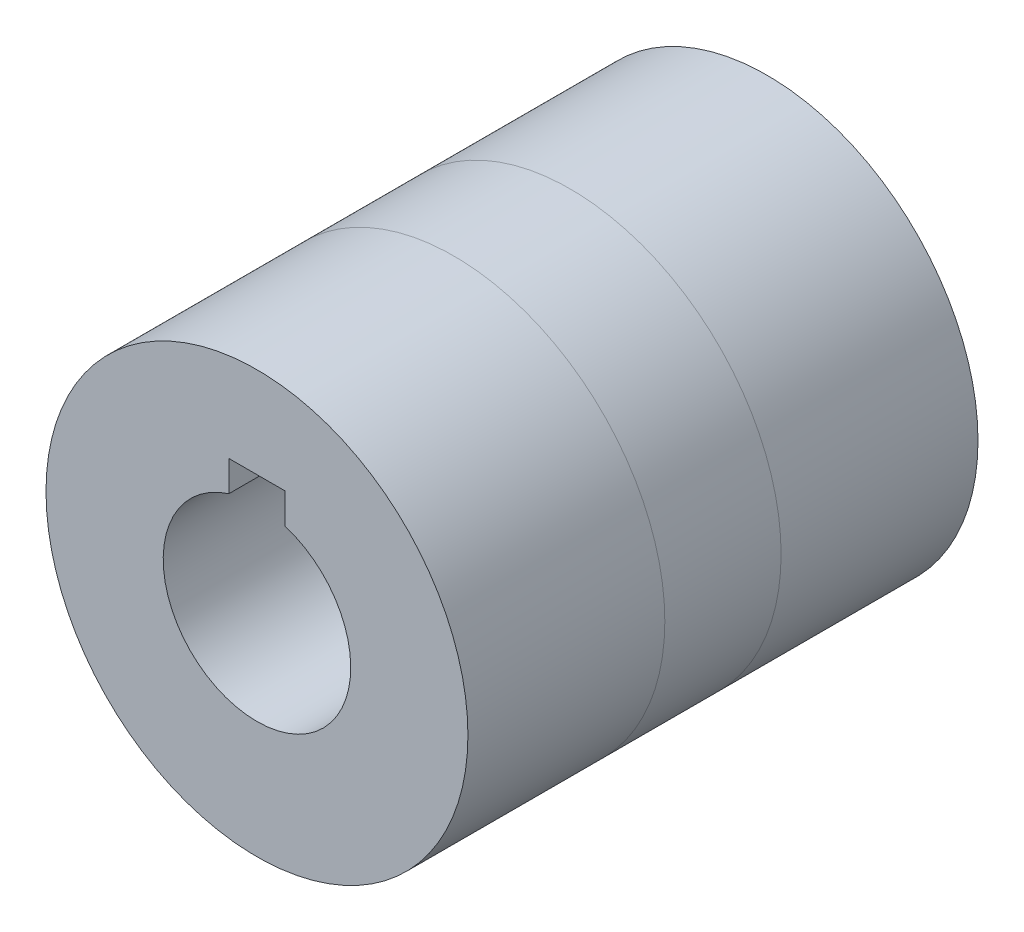
from build123d import *

# Parameters (mm, degrees)
SKETCH_1_R          = 22.5
SKETCH_1_R_2        = 10
EXTRUDE_1_DEPTH     = 6.2
SKETCH_3_R          = 22.5
SKETCH_3_R_2        = 10
EXTRUDE_2_DEPTH     = 21
SKETCH_4_R          = 22.5
SKETCH_4_R_2        = 10
EXTRUDE_3_DEPTH     = 21
SKETCH_6_W          = 6
SKETCH_6_H          = 5.6
CUT_EXTRUDE_1_DEPTH = 55.4


with BuildPart() as part:
    # 草图1 → 凸台-拉伸1 (new body, symmetric)
    with BuildSketch(Plane.XY):
        Circle(SKETCH_1_R)
        Circle(SKETCH_1_R_2, mode=Mode.SUBTRACT)
    extrude(amount=EXTRUDE_1_DEPTH, both=True)


with BuildPart() as body_2:
    # 草图3 → 凸台-拉伸2 (new body)
    with BuildSketch(Plane.XY.offset(6.2)):
        Circle(SKETCH_3_R)
        Circle(SKETCH_3_R_2, mode=Mode.SUBTRACT)
    extrude(amount=EXTRUDE_2_DEPTH)


with BuildPart() as body_3:
    # 草图4 → 凸台-拉伸3 (new body)
    with BuildSketch(Plane(origin=(0, 0, -6.2), x_dir=(-1, 0, 0), z_dir=(0, 0, -1))):
        Circle(SKETCH_4_R)
        Circle(SKETCH_4_R_2, mode=Mode.SUBTRACT)
    extrude(amount=EXTRUDE_3_DEPTH)


with BuildPart() as cut_extrude_1_tool:
    # 草图6 → 切除-拉伸1 (new body, through all)
    with BuildSketch(Plane.XY.offset(27.2)):
        with Locations((0, 10)):
            Rectangle(SKETCH_6_W, SKETCH_6_H)
    extrude(amount=-CUT_EXTRUDE_1_DEPTH)


with BuildPart() as part_1:
    add(part.part)

    # 切除-拉伸1: cut by cut_extrude_1_tool
    add(cut_extrude_1_tool.part, mode=Mode.SUBTRACT)


with BuildPart() as body_2_1:
    add(body_2.part)

    # 切除-拉伸1: cut by cut_extrude_1_tool
    add(cut_extrude_1_tool.part, mode=Mode.SUBTRACT)


with BuildPart() as body_3_1:
    add(body_3.part)

    # 切除-拉伸1: cut by cut_extrude_1_tool
    add(cut_extrude_1_tool.part, mode=Mode.SUBTRACT)


solid = Compound([part_1.part, body_2_1.part, body_3_1.part])
